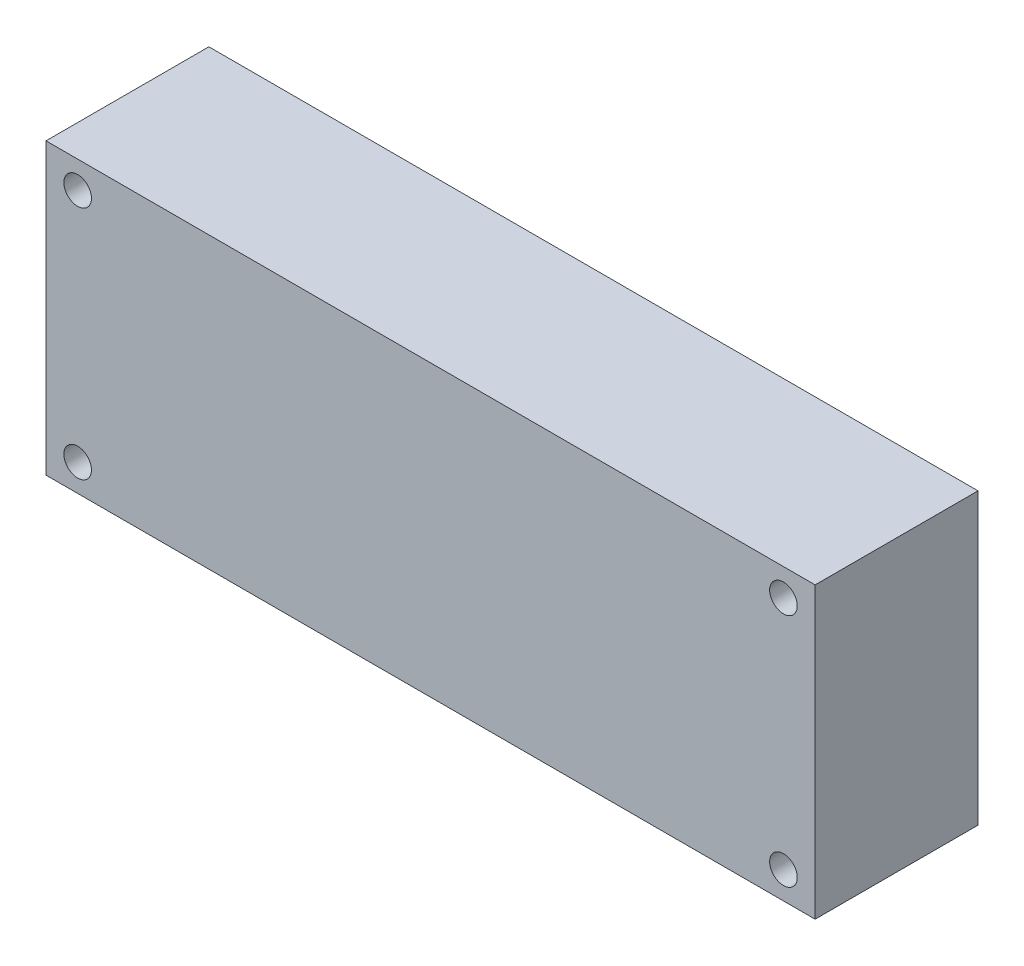
from build123d import *

# Parameters (mm, degrees)
SKETCH_1_W               = 85
SKETCH_1_H               = 32
EXTRUDE_1_DEPTH          = 18
SKETCH_2_R               = 1.525
CUT_EXTRUDE_1_DEPTH      = 1
CUT_EXTRUDE_1_DEPTH_BACK = 19


with BuildPart() as part:
    # 草图1 → 凸台-拉伸1 (new body)
    with BuildSketch(Plane.XY):
        Rectangle(SKETCH_1_W, SKETCH_1_H)
    extrude(amount=EXTRUDE_1_DEPTH)

    # 草图2 → 切除-拉伸1 (cut, two sides)
    with BuildSketch(Plane.XY.offset(18)) as cut_extrude_1_sk:
        with Locations((39, 13)):
            Circle(SKETCH_2_R)
        with Locations((39, -13)):
            Circle(SKETCH_2_R)
        with Locations((-39, -13)):
            Circle(SKETCH_2_R)
        with Locations((-39, 13)):
            Circle(SKETCH_2_R)
    extrude(amount=CUT_EXTRUDE_1_DEPTH, mode=Mode.SUBTRACT)
    extrude(cut_extrude_1_sk.sketch, amount=-CUT_EXTRUDE_1_DEPTH_BACK, mode=Mode.SUBTRACT)


solid = part.part
